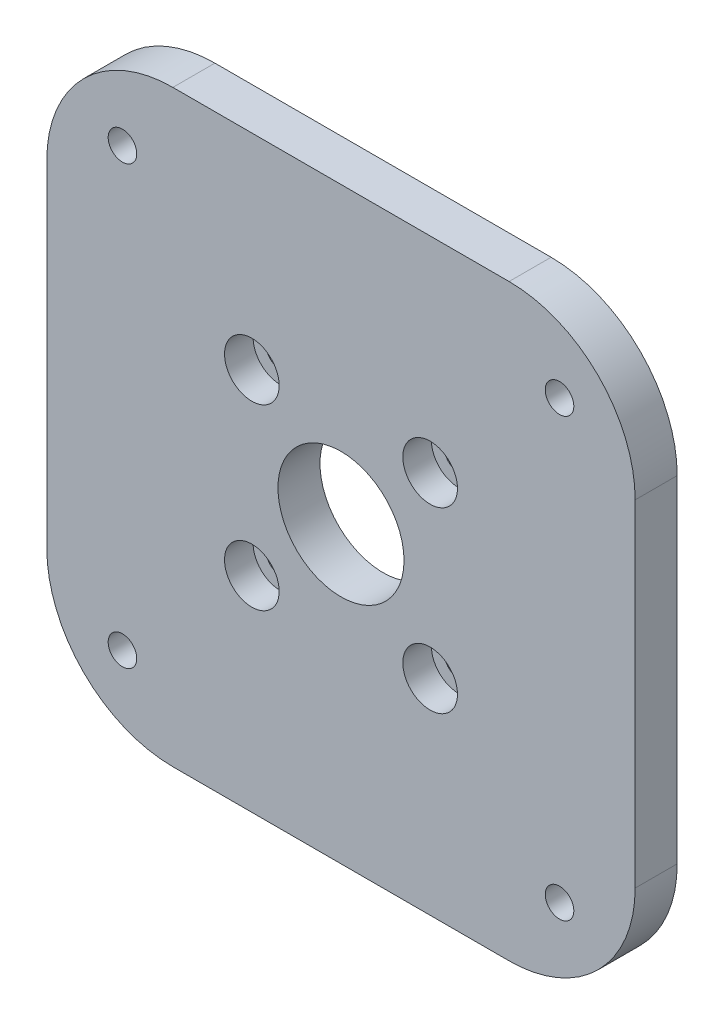
from build123d import *

# Parameters (mm, degrees)
SKETCH1_W                                           = 70
SKETCH1_H                                           = 70
BOSS_EXTRUDE1_DEPTH                                 = 5
FILLET1_R                                           = 15
CBORE_FOR_M3_HEX_SOCKET_HEAD_CAP_SCREW1_D           = 3.4
CBORE_FOR_M3_HEX_SOCKET_HEAD_CAP_SCREW1_CBORE_D     = 6.5
CBORE_FOR_M3_HEX_SOCKET_HEAD_CAP_SCREW1_CBORE_DEPTH = 3.4
SKETCH5_R                                           = 7.5
CUT_EXTRUDE1_DEPTH                                  = 6
M3_CLEARANCE_HOLE1_D                                = 3.4


with BuildPart() as part:
    # Sketch1 → Boss-Extrude1 (new body)
    with BuildSketch(Plane.XY):
        Rectangle(SKETCH1_W, SKETCH1_H)
    extrude(amount=BOSS_EXTRUDE1_DEPTH)

    # Fillet1
    fillet1_edges = [part.edges().sort_by_distance(p)[0] for p in [
        (35, -35, 2.5),
        (-35, -35, 2.5),
        (-35, 35, 2.5),
        (35, 35, 2.5),
    ]]
    fillet(fillet1_edges, radius=FILLET1_R)

    # CBORE for M3 Hex Socket Head Cap Screw1 (through all)
    with Locations(Plane.XY.offset(5)):
        with Locations((-10.606601718, -10.606601718), (-10.606601718, 10.606601718), (10.606601718, 10.606601718), (10.606601718, -10.606601718)):
            CounterBoreHole(CBORE_FOR_M3_HEX_SOCKET_HEAD_CAP_SCREW1_D / 2, CBORE_FOR_M3_HEX_SOCKET_HEAD_CAP_SCREW1_CBORE_D / 2, CBORE_FOR_M3_HEX_SOCKET_HEAD_CAP_SCREW1_CBORE_DEPTH)

    # Sketch5 → Cut-Extrude1 (cut, through all)
    with BuildSketch(Plane.XY.offset(5)):
        Circle(SKETCH5_R)
    extrude(amount=-CUT_EXTRUDE1_DEPTH, mode=Mode.SUBTRACT)

    # M3 Clearance Hole1 (through all)
    with Locations(Plane.XY.offset(5)):
        with Locations((26, 26), (-26, 26), (-26, -26), (26, -26)):
            Hole(M3_CLEARANCE_HOLE1_D / 2)


solid = part.part
